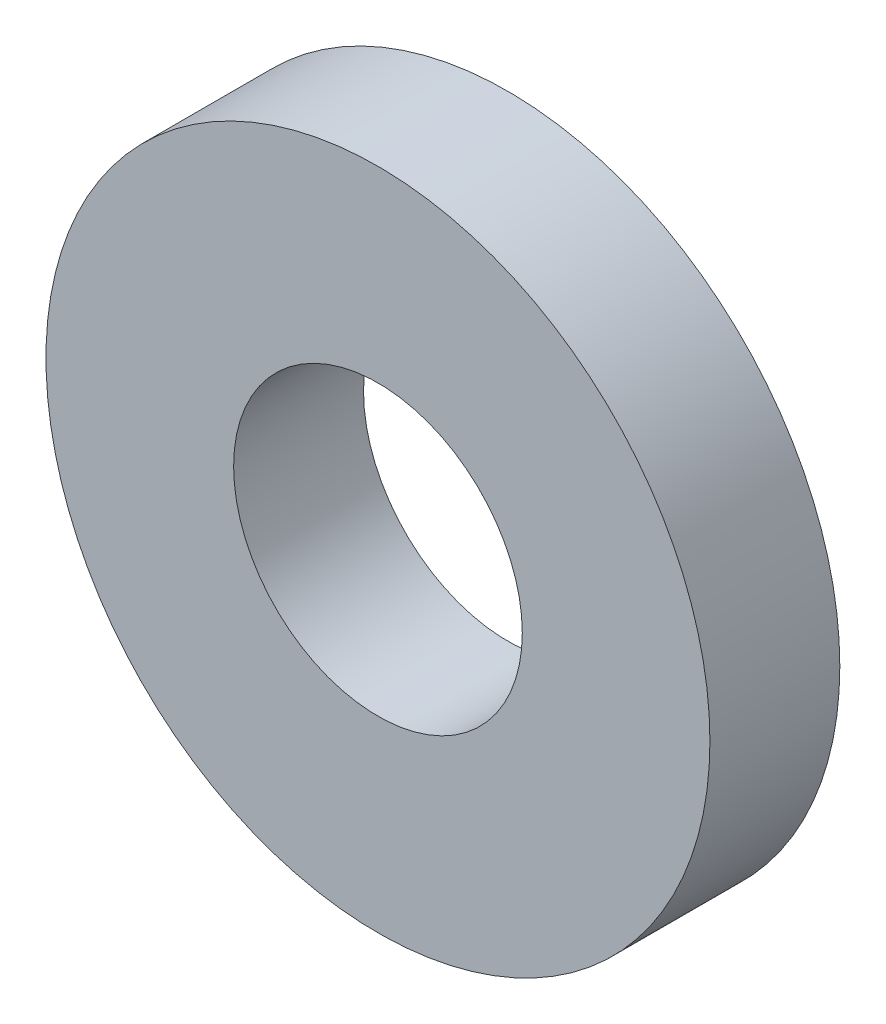
from build123d import *

# Parameters (mm, degrees)
SKETCH_1_R      = 23
SKETCH_1_R_2    = 10
EXTRUDE_1_DEPTH = 9


with BuildPart() as part:
    # Эскиз1 → Бобышка-Вытянуть1 (new body)
    with BuildSketch(Plane.XY):
        Circle(SKETCH_1_R)
        Circle(SKETCH_1_R_2, mode=Mode.SUBTRACT)
    extrude(amount=EXTRUDE_1_DEPTH)


solid = part.part
